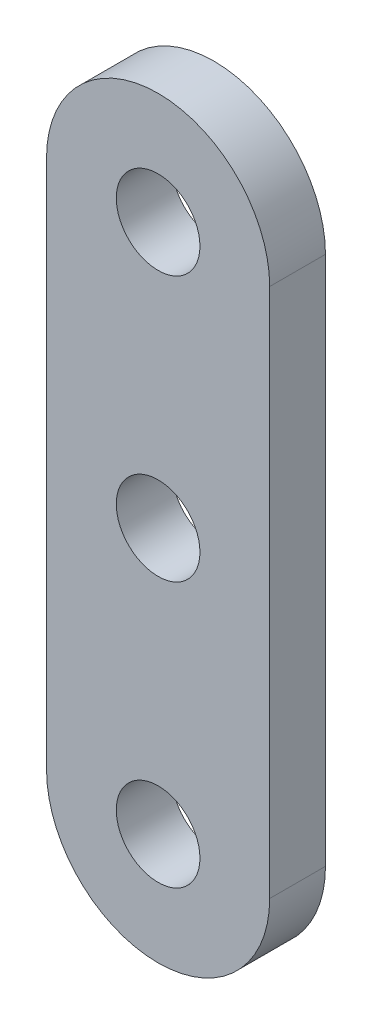
from build123d import *

# Parameters (mm, degrees)
SKETCH1_R           = 2.38125
BOSS_EXTRUDE1_DEPTH = 3.175
SKETCH2_R           = 2.38125
CUT_EXTRUDE1_DEPTH  = 3.175


with BuildPart() as part:
    # Sketch1 → Boss-Extrude1 (new body)
    with BuildSketch(Plane.XY):
        with BuildLine():
            Line((-6.35, 0), (-6.35, 30.1625))
            ThreePointArc((-6.35, 30.1625), (0, 36.5125), (6.35, 30.1625))
            Line((6.35, 30.1625), (6.35, 0))
            ThreePointArc((6.35, 0), (0, -6.35), (-6.35, 0))
        make_face()
        Circle(SKETCH1_R, mode=Mode.SUBTRACT)
        with Locations((0, 30.1625)):
            Circle(SKETCH1_R, mode=Mode.SUBTRACT)
    extrude(amount=BOSS_EXTRUDE1_DEPTH)

    # Sketch2 → Cut-Extrude1 (cut)
    with BuildSketch(Plane.XY.offset(3.175)):
        with Locations((0, 15.08125)):
            Circle(SKETCH2_R)
    extrude(amount=-CUT_EXTRUDE1_DEPTH, mode=Mode.SUBTRACT)


solid = part.part
